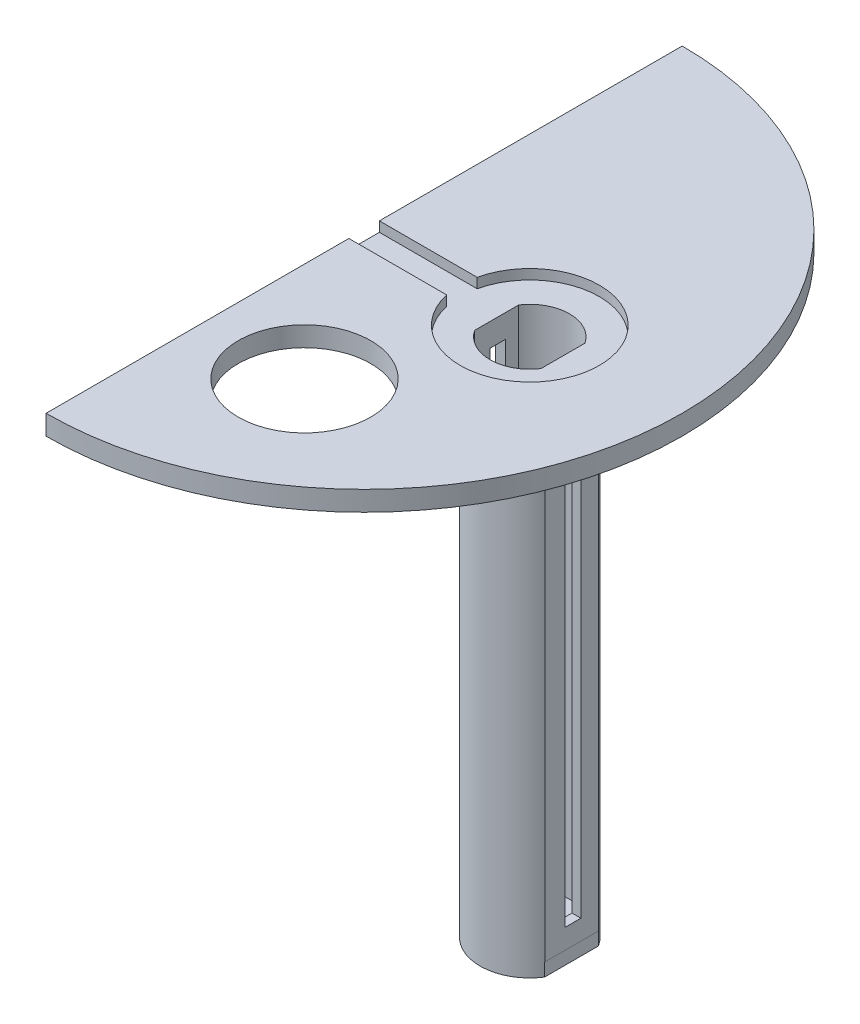
from build123d import *

# Parameters (mm, degrees)
BOSS_EXTRUDE2_DEPTH = 3
CUT_EXTRUDE1_DEPTH  = 1.5
CUT_EXTRUDE4_DEPTH  = 4
BOSS_EXTRUDE4_DEPTH = 75
BOSS_EXTRUDE6_DEPTH = 2
SKETCH9_W           = 2.4
SKETCH9_H           = 70
CUT_EXTRUDE5_DEPTH  = 20
SKETCH11_R          = 10
CUT_EXTRUDE6_DEPTH  = 4


with BuildPart() as part:
    # Sketch2 → Boss-Extrude2 (new body)
    with BuildSketch(Plane(origin=(0, 0, 0), x_dir=(1, 0, 0), z_dir=(0, 1, 0))):
        with BuildLine():
            Line((0, 48), (0, -48))
            ThreePointArc((0, -48), (48, 0), (0, 48))
        make_face()
    extrude(amount=BOSS_EXTRUDE2_DEPTH)

    # Sketch3 → Cut-Extrude1 (cut)
    with BuildSketch(Plane(origin=(0, 3, 0), x_dir=(1, 0, 0), z_dir=(0, 1, 0))):
        with BuildLine():
            Line((14.75500122, 2.3), (0, 2.3))
            Line((0, 2.3), (0, -2.3))
            Line((0, -2.3), (14.75500122, -2.3))
            ThreePointArc((14.75500122, -2.3), (35.5, 0), (14.75500122, 2.3))
        make_face()
    extrude(amount=-CUT_EXTRUDE1_DEPTH, mode=Mode.SUBTRACT)

    # Sketch4 → Cut-Extrude4 (cut)
    with BuildSketch(Plane(origin=(0, 1.5, 0), x_dir=(1, 0, 0), z_dir=(0, 1, 0))):
        with BuildLine():
            Line((20, 3.31662479), (20, -3.31662479))
            ThreePointArc((20, -3.31662479), (25, -6), (30, -3.31662479))
            Line((30, -3.31662479), (30, 3.31662479))
            ThreePointArc((30, 3.31662479), (25, 6), (20, 3.31662479))
        make_face()
    extrude(amount=-CUT_EXTRUDE4_DEPTH, mode=Mode.SUBTRACT)

    # Sketch6 → Boss-Extrude4 (add)
    with BuildSketch(Plane.XZ):
        with BuildLine():
            Line((18.423549772, 3.60559321), (18.423549772, -3.60559321))
            ThreePointArc((18.423549772, -3.60559321), (24.766267094, -7.496357044), (31.339052831, -4.008292554))
            Line((31.339052831, -4.008292554), (31.339052831, 4.008292554))
            ThreePointArc((31.339052831, 4.008292554), (24.766267094, 7.496357044), (18.423549772, 3.60559321))
        make_face()
        with BuildLine():
            Line((20, 3.31662479), (20, -3.31662479))
            ThreePointArc((20, -3.31662479), (25, -6), (30, -3.31662479))
            Line((30, -3.31662479), (30, 3.31662479))
            ThreePointArc((30, 3.31662479), (25, 6), (20, 3.31662479))
        make_face(mode=Mode.SUBTRACT)
    extrude(amount=BOSS_EXTRUDE4_DEPTH)

    # Sketch8 → Boss-Extrude6 (add)
    with BuildSketch(Plane.XZ.offset(75)):
        with BuildLine():
            Line((18.4, 3.562302626), (18.4, -3.562302626))
            ThreePointArc((18.4, -3.562302626), (24.705404639, -7.494212005), (31.3, -4.06939799))
            Line((31.3, -4.06939799), (31.3, 4.06939799))
            ThreePointArc((31.3, 4.06939799), (24.705404639, 7.494212005), (18.4, 3.562302626))
        make_face()
    extrude(amount=BOSS_EXTRUDE6_DEPTH)

    # Sketch9 → Cut-Extrude5 (cut)
    with BuildSketch(Plane.ZY.offset(-18.423549772)):
        with Locations((-0.170167771, -37)):
            Rectangle(SKETCH9_W, SKETCH9_H)
    extrude(amount=-CUT_EXTRUDE5_DEPTH, mode=Mode.SUBTRACT)

    # Sketch11 → Cut-Extrude6 (cut)
    with BuildSketch(Plane(origin=(0, 3, 0), x_dir=(1, 0, 0), z_dir=(0, 1, 0))):
        with Locations((15, -24)):
            Circle(SKETCH11_R)
    extrude(amount=-CUT_EXTRUDE6_DEPTH, mode=Mode.SUBTRACT)


solid = part.part
